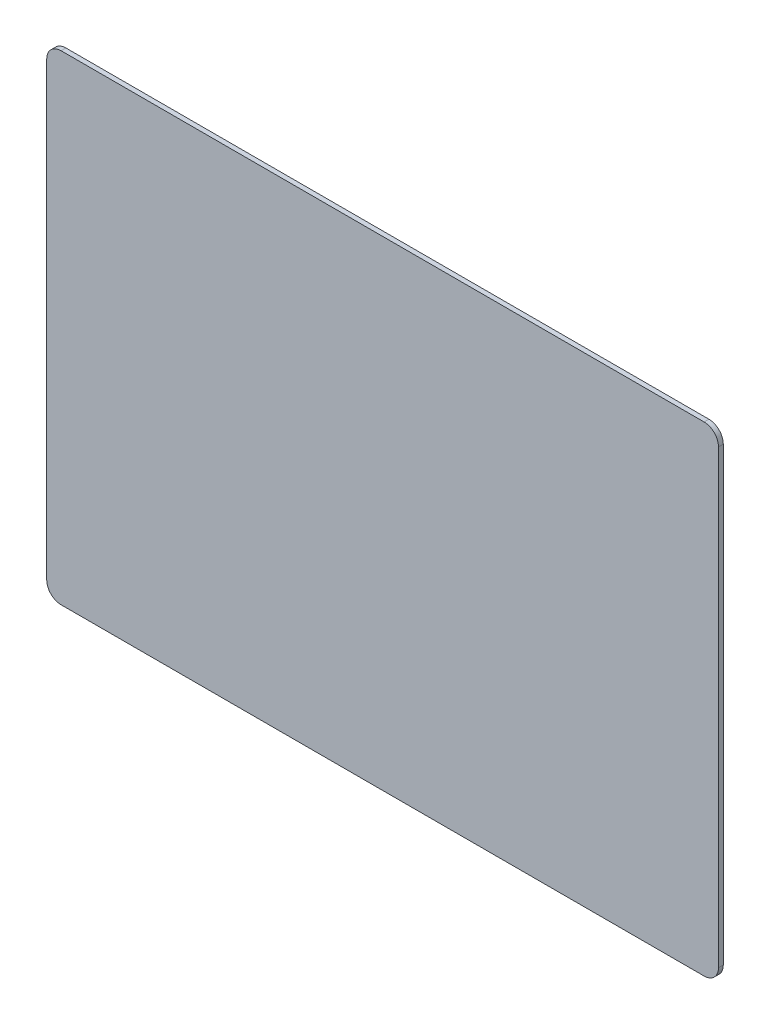
from build123d import *

# Parameters (mm, degrees)
SKIZZE1_W                       = 140
SKIZZE1_H                       = 100
AUFSATZ_LINEAR_AUSTRAGEN1_DEPTH = 1
VERRUNDUNG1_R                   = 3


with BuildPart() as part:
    # Skizze1 → Aufsatz-Linear austragen1 (new body)
    with BuildSketch(Plane.XY):
        Rectangle(SKIZZE1_W, SKIZZE1_H)
    extrude(amount=-AUFSATZ_LINEAR_AUSTRAGEN1_DEPTH)

    # Verrundung1
    verrundung1_edges = [part.edges().sort_by_distance(p)[0] for p in [
        (70, -50, -0.5),
        (-70, -50, -0.5),
        (-70, 50, -0.5),
        (70, 50, -0.5),
    ]]
    fillet(verrundung1_edges, radius=VERRUNDUNG1_R)


solid = part.part
